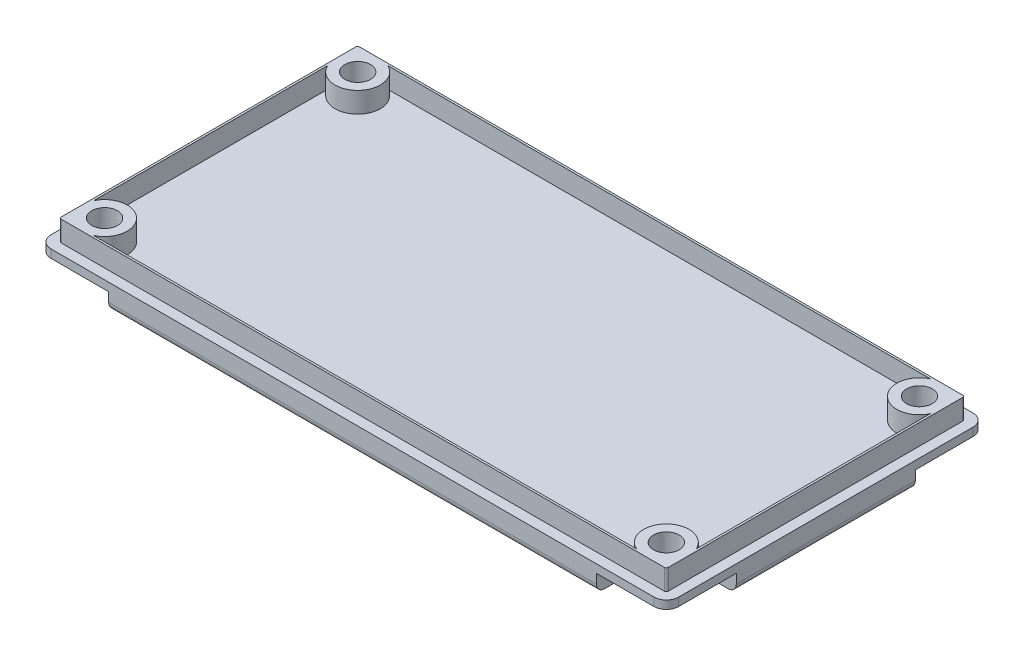
from build123d import *

# Parameters (mm, degrees)
SKETCH1_R            = 0.79375
EXTRUDE1_DEPTH       = 1.5875
FILLET2_R            = 0.508
SKETCH2_R            = 0.79375
EXTRUDE2_DEPTH       = 1.27
CUT_EXTRUDE1_DEPTH   = 1.0795
MIRROR2_COPY_1_DEPTH = 1.0795


with BuildPart() as part:
    # Sketch1 → Extrude1 (new body)
    with BuildSketch(Plane(origin=(0, 0, 0), x_dir=(1, 0, 0), z_dir=(0, 1, 0))):
        with BuildLine():
            Line((-18.6055, 9.8425), (18.6055, 9.8425))
            ThreePointArc((18.6055, 9.8425), (19.144315367, 9.619315367), (19.3675, 9.0805))
            Line((19.3675, 9.0805), (19.3675, -9.0805))
            ThreePointArc((19.3675, -9.0805), (19.144315367, -9.619315367), (18.6055, -9.8425))
            Line((18.6055, -9.8425), (-18.6055, -9.8425))
            ThreePointArc((-18.6055, -9.8425), (-19.144315367, -9.619315367), (-19.3675, -9.0805))
            Line((-19.3675, -9.0805), (-19.3675, 9.0805))
            ThreePointArc((-19.3675, 9.0805), (-19.144315367, 9.619315367), (-18.6055, 9.8425))
        make_face()
        with Locations((-17.3355, 7.8105)):
            Circle(SKETCH1_R, mode=Mode.SUBTRACT)
        with Locations((17.3355, 7.8105)):
            Circle(SKETCH1_R, mode=Mode.SUBTRACT)
        with Locations((17.3355, -7.8105)):
            Circle(SKETCH1_R, mode=Mode.SUBTRACT)
        with Locations((-17.3355, -7.8105)):
            Circle(SKETCH1_R, mode=Mode.SUBTRACT)
    extrude(amount=EXTRUDE1_DEPTH)

    # Fillet2
    fillet2_edges = [part.edges().sort_by_distance(p)[0] for p in [
        (-19.3675, 0, 0),
        (-19.144315367, 0, -9.619315367),
        (0, 0, -9.8425),
        (19.144315367, 0, -9.619315367),
        (19.3675, 0, 0),
        (19.144315367, 0, 9.619315367),
        (0, 0, 9.8425),
        (-19.144315367, 0, 9.619315367),
    ]]
    fillet(fillet2_edges, radius=FILLET2_R)

    # Sketch2 → Extrude2 (add)
    with BuildSketch(Plane(origin=(0, 1.5875, 0), x_dir=(-1, 0, 0), z_dir=(0, 1, 0))):
        with BuildLine():
            Line((18.6055, 9.2075), (-18.6055, 9.2075))
            ThreePointArc((-18.6055, 9.2075), (-18.695302561, 9.170302561), (-18.7325, 9.0805))
            Line((-18.7325, 9.0805), (-18.7325, -9.0805))
            ThreePointArc((-18.7325, -9.0805), (-18.695302561, -9.170302561), (-18.6055, -9.2075))
            Line((-18.6055, -9.2075), (18.6055, -9.2075))
            ThreePointArc((18.6055, -9.2075), (18.695302561, -9.170302561), (18.7325, -9.0805))
            Line((18.7325, -9.0805), (18.7325, 9.0805))
            ThreePointArc((18.7325, 9.0805), (18.695302561, 9.170302561), (18.6055, 9.2075))
        make_face()
        with Locations((-17.3355, 7.8105)):
            Circle(SKETCH2_R, mode=Mode.SUBTRACT)
        with Locations((-17.3355, -7.8105)):
            Circle(SKETCH2_R, mode=Mode.SUBTRACT)
        with Locations((17.3355, -7.8105)):
            Circle(SKETCH2_R, mode=Mode.SUBTRACT)
        with Locations((17.3355, 7.8105)):
            Circle(SKETCH2_R, mode=Mode.SUBTRACT)
        with BuildLine():
            Line((-18.6055, -7.228512887), (-18.6055, 7.228512887))
            ThreePointArc((-18.6055, 7.228512887), (-16.347671827, 6.822671827), (-16.753512887, 9.0805))
            Line((-16.753512887, 9.0805), (16.753512887, 9.0805))
            ThreePointArc((16.753512887, 9.0805), (16.347671827, 6.822671827), (18.6055, 7.228512887))
            Line((18.6055, 7.228512887), (18.6055, -7.228512887))
            ThreePointArc((18.6055, -7.228512887), (16.347671827, -6.822671827), (16.753512887, -9.0805))
            Line((16.753512887, -9.0805), (-16.753512887, -9.0805))
            ThreePointArc((-16.753512887, -9.0805), (-16.347671827, -6.822671827), (-18.6055, -7.228512887))
        make_face(mode=Mode.SUBTRACT)
    extrude(amount=EXTRUDE2_DEPTH)

    # Sketch3 → Cut-Extrude1 (cut)
    with BuildSketch(Plane.XZ):
        with BuildLine():
            Line((-16.3195, -5.5245), (-19.3675, -5.5245))
            Line((-19.3675, -5.5245), (-19.3675, -9.8425))
            Line((-19.3675, -9.8425), (-15.0495, -9.8425))
            Line((-15.0495, -9.8425), (-15.0495, -6.7945))
            ThreePointArc((-15.0495, -6.7945), (-15.421474388, -5.896474388), (-16.3195, -5.5245))
        make_face()
    cut_extrude1 = extrude(amount=-CUT_EXTRUDE1_DEPTH, mode=Mode.SUBTRACT)

    # Mirror1: Cut-Extrude1 across plane
    add(cut_extrude1.mirror(Plane(origin=(0, 0, 0), x_dir=(0, 0, 1), z_dir=(1, 0, 0))), mode=Mode.SUBTRACT)

    # Mirror2: Cut-Extrude1 across plane
    add(cut_extrude1.mirror(Plane.XY), mode=Mode.SUBTRACT)

    # Mirror2 copy 1 sketch → Mirror2 copy 1 (cut)
    with BuildSketch(Plane(origin=(0, 0, 0), x_dir=(-1, 0, 0), z_dir=(0, -1, 0))):
        with BuildLine():
            Line((-16.3195, -5.5245), (-19.3675, -5.5245))
            Line((-19.3675, -5.5245), (-19.3675, -9.8425))
            Line((-19.3675, -9.8425), (-15.0495, -9.8425))
            Line((-15.0495, -9.8425), (-15.0495, -6.7945))
            ThreePointArc((-15.0495, -6.7945), (-15.421474388, -5.896474388), (-16.3195, -5.5245))
        make_face()
    extrude(amount=-MIRROR2_COPY_1_DEPTH, mode=Mode.SUBTRACT)


solid = part.part
